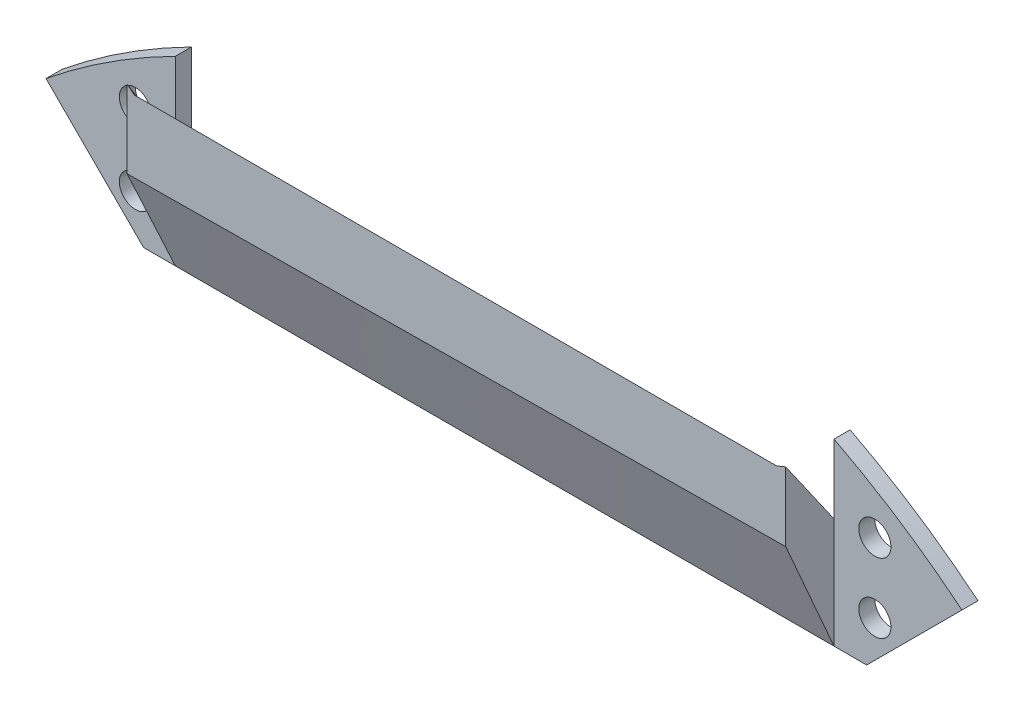
from build123d import *

# Parameters (mm, degrees)
BOSS_EXTRUDE1_DEPTH = 2
SKETCH4_R           = 1.999996
CUT_EXTRUDE2_DEPTH  = 3


with BuildPart() as part:
    # Sketch2 → Boss-Extrude1 (new body)
    with BuildSketch(Plane.XY):
        with BuildLine():
            Line((369.86928226, 192.180584327), (358.0270208, 180.34))
            Line((358.0270208, 180.34), (268.1110208, 180.34))
            Line((268.1110208, 180.34), (255.978033197, 192.47289829))
            ThreePointArc((255.978033197, 192.47289829), (263.741388347, 198.123056954), (272.0624988, 202.913996))
            Line((272.0624988, 202.913996), (272.0624988, 193.261996))
            Line((272.0624988, 193.261996), (277.7630208, 185.928))
            Line((277.7630208, 185.928), (347.8670208, 185.928))
            Line((347.8670208, 185.928), (353.9630208, 194.056))
            Line((353.9630208, 194.056), (353.9630208, 202.64014406))
            ThreePointArc((353.9630208, 202.64014406), (362.193484504, 197.832115291), (369.86928226, 192.180584327))
        make_face()
    extrude(amount=BOSS_EXTRUDE1_DEPTH)

    # Sketch4 → Cut-Extrude2 (cut, through all)
    with BuildSketch(Plane(origin=(0, 0, 0), x_dir=(-1, 0, 0), z_dir=(0, 0, -1))):
        with Locations((-359.0430208, 194.564)):
            Circle(SKETCH4_R)
        with Locations((-359.0430208, 185.928)):
            Circle(SKETCH4_R)
        with Locations((-267.0950208, 185.928)):
            Circle(SKETCH4_R)
        with Locations((-267.0950208, 195.072)):
            Circle(SKETCH4_R)
    extrude(amount=-CUT_EXTRUDE2_DEPTH, mode=Mode.SUBTRACT)

    # Sketch5 → Loft4 section 0
    with BuildSketch(Plane.XY.offset(2)):
        Polygon((272.0624988, 193.261996), (272.0624988, 180.34), (353.9630208, 180.34), (353.9630208, 194.056), (347.8670208, 185.928), (277.7630208, 185.928), align=None)
    # Sketch6 → Loft4 section 1
    with BuildSketch(Plane.XY.offset(8)):
        Polygon((272.0624988, 202.913996), (272.0624988, 193.261996), (353.9630208, 194.056), (353.9630208, 202.64014406), (352.808404878, 202.184642252), (272.968388735, 202.184642252), align=None)
    loft()


solid = part.part
